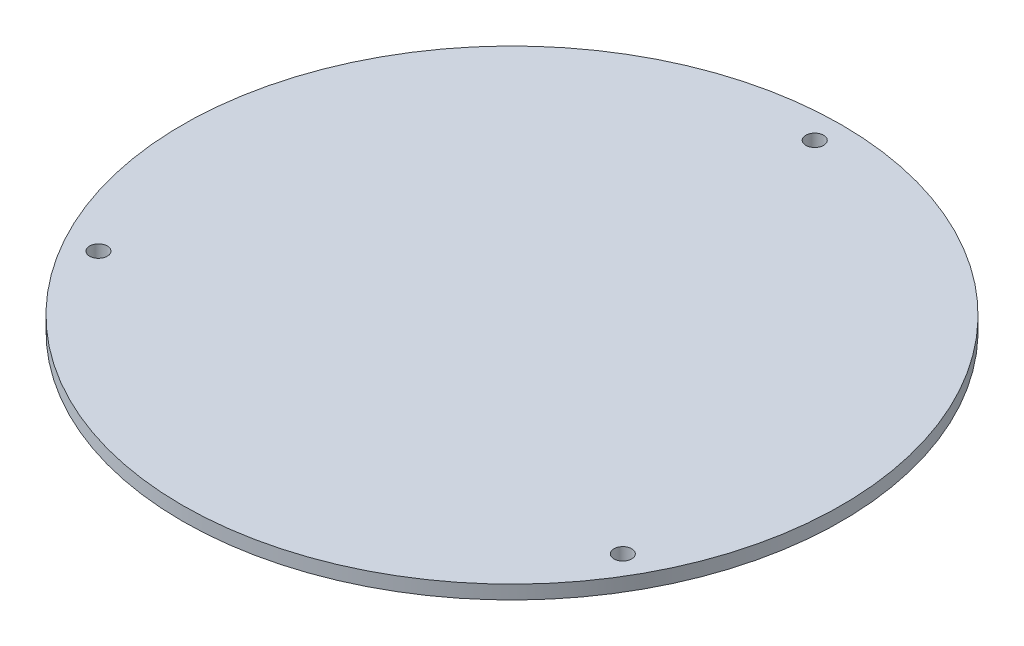
from build123d import *

# Parameters (mm, degrees)
SKETCH1_R           = 152.4
BOSS_EXTRUDE1_DEPTH = 6.35
SKETCH2_R           = 4.1
CUT_EXTRUDE1_DEPTH  = 7.35
CIRPATTERN1_COUNT   = 3


with BuildPart() as part:
    # Sketch1 → Boss-Extrude1 (new body)
    with BuildSketch(Plane(origin=(0, 0, 0), x_dir=(1, 0, 0), z_dir=(0, 1, 0))):
        Circle(SKETCH1_R)
    extrude(amount=BOSS_EXTRUDE1_DEPTH)

    # Sketch2 → Cut-Extrude1 (cut, through all)
    with BuildSketch(Plane(origin=(0, 6.35, 0), x_dir=(1, 0, 0), z_dir=(0, 1, 0))):
        with Locations((0, 140)):
            Circle(SKETCH2_R)
    cut_extrude1 = extrude(amount=-CUT_EXTRUDE1_DEPTH, mode=Mode.SUBTRACT)

    # CirPattern1: Cut-Extrude1 ×3 about axis
    cirpattern1_axis = Axis((0, 0, 0), (0, 1, 0))
    for i in range(1, CIRPATTERN1_COUNT):
        add(cut_extrude1.rotate(cirpattern1_axis, i * 360 / CIRPATTERN1_COUNT), mode=Mode.SUBTRACT)


solid = part.part
